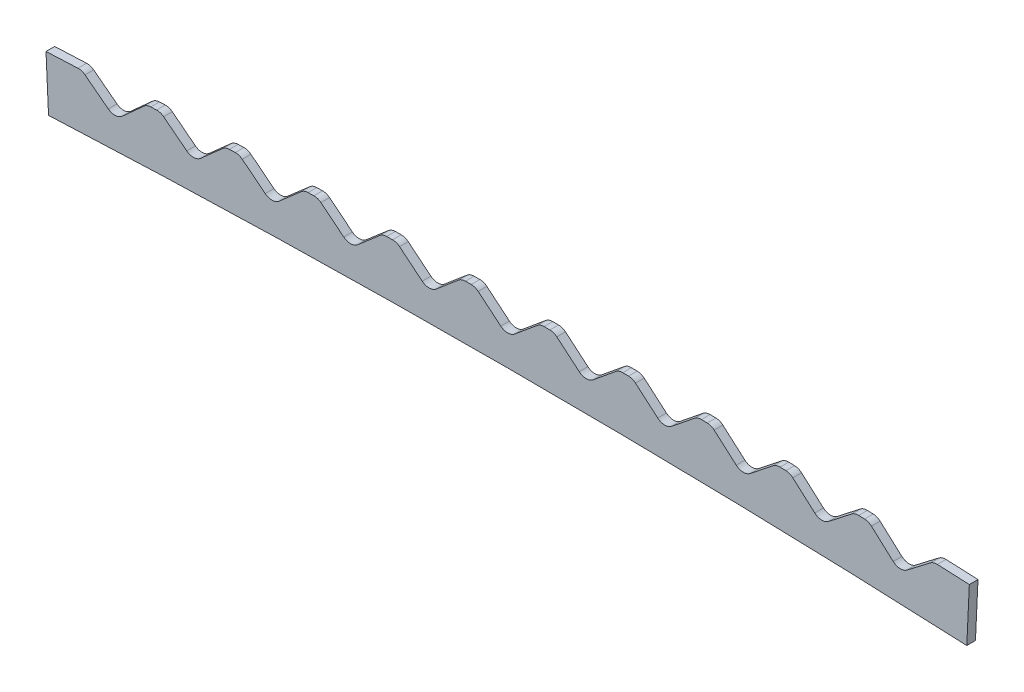
from build123d import *

# Parameters (mm, degrees)
BOSS_EXTRU_2_DEPTH                 = 8
ENL_V_MAT_EXTRU_1_DEPTH            = 9
CONG_1_R                           = 10
R_P_TITION_CIRCULAIRE1_COUNT       = 6
R_P_TITION_CIRCULAIRE1_ANGLE       = 2.3
CONG_1_OF_R_P_TITION_CIRCULAIRE1_R = 10
R_P_TITION_CIRCULAIRE2_COUNT       = 6
R_P_TITION_CIRCULAIRE2_ANGLE       = 2.3
CONG_1_OF_R_P_TITION_CIRCULAIRE2_R = 10


with BuildPart() as part:
    # Esquisse1 → Boss.-Extru.2 (new body)
    with BuildSketch(Plane.XY):
        with BuildLine():
            Line((423.958056387, -9.991125342), (426.313378922, 39.953368406))
            ThreePointArc((426.313378922, 39.953368406), (0, 50), (-426.313378922, 39.953368406))
            Line((-426.313378922, 39.953368406), (-423.958056387, -9.991125342))
            ThreePointArc((-423.958056387, -9.991125342), (0, 0), (423.958056387, -9.991125342))
        make_face()
    extrude(amount=BOSS_EXTRU_2_DEPTH)

    # Esquisse2 → Enlèv. mat.-Extru.1 (cut, through all)
    with BuildSketch(Plane.XY.offset(8)):
        Polygon((0, 25), (30, 49.950276106), (0, 74.995327729), (-30, 49.950276106), align=None)
    enl_v_mat_extru_1 = extrude(amount=-ENL_V_MAT_EXTRU_1_DEPTH, mode=Mode.SUBTRACT)

    # Congé1
    cong_1_edges = [part.edges().sort_by_distance(p)[0] for p in [
        (0, 25, 4),
        (-30, 49.950276106, 4),
        (30, 49.950276106, 4),
    ]]
    fillet(cong_1_edges, radius=CONG_1_R)

    # Répétition circulaire1: Enlèv. mat.-Extru.1 ×6 about axis
    r_p_tition_circulaire1_axis = Axis((0, -9000, 0), (0, 0, 1))
    for i in range(1, R_P_TITION_CIRCULAIRE1_COUNT):
        add(enl_v_mat_extru_1.rotate(r_p_tition_circulaire1_axis, i * R_P_TITION_CIRCULAIRE1_ANGLE / (R_P_TITION_CIRCULAIRE1_COUNT - 1)), mode=Mode.SUBTRACT)

    # Congé1 of Répétition circulaire1
    cong_1_of_r_p_tition_circulaire1_edges = [part.edges().sort_by_distance(p)[0] for p in [
        (-72.456565501, 24.709139142, 4),
        (-102.655910154, 49.417758293, 4),
        (-42.657843855, 49.899463992, 4),
        (-144.908460692, 23.836575317, 4),
        (-175.305203447, 48.301944876, 4),
        (-115.312938126, 49.265325224, 4),
        (-217.351015561, 22.382364766, 4),
        (-247.943197144, 46.602907776, 4),
        (-187.960599706, 48.047900678, 4),
        (-289.779560701, 20.346601223, 4),
        (-320.565209242, 44.320756509, 4),
        (-260.596145965, 46.247268824, 4),
        (-362.189427606, 17.729415908, 4),
        (-393.166558764, 41.455638174, 4),
        (-333.214895057, 43.863545726, 4),
    ]]
    fillet(cong_1_of_r_p_tition_circulaire1_edges, radius=CONG_1_OF_R_P_TITION_CIRCULAIRE1_R)

    # Répétition circulaire2: Enlèv. mat.-Extru.1 ×6 about axis
    r_p_tition_circulaire2_axis = Axis((0, -9000, 0), (0, 0, -1))
    for i in range(1, R_P_TITION_CIRCULAIRE2_COUNT):
        add(enl_v_mat_extru_1.rotate(r_p_tition_circulaire2_axis, i * R_P_TITION_CIRCULAIRE2_ANGLE / (R_P_TITION_CIRCULAIRE2_COUNT - 1)), mode=Mode.SUBTRACT)

    # Congé1 of Répétition circulaire2
    cong_1_of_r_p_tition_circulaire2_edges = [part.edges().sort_by_distance(p)[0] for p in [
        (72.456565501, 24.709139142, 4),
        (42.657843855, 49.899463992, 4),
        (102.655910154, 49.417758293, 4),
        (144.908460692, 23.836575317, 4),
        (115.312938126, 49.265325224, 4),
        (175.305203447, 48.301944876, 4),
        (217.351015561, 22.382364766, 4),
        (187.960599706, 48.047900678, 4),
        (247.943197144, 46.602907776, 4),
        (289.779560701, 20.346601223, 4),
        (260.596145965, 46.247268824, 4),
        (320.565209242, 44.320756509, 4),
        (362.189427606, 17.729415908, 4),
        (333.214895057, 43.863545726, 4),
        (393.166558764, 41.455638174, 4),
    ]]
    fillet(cong_1_of_r_p_tition_circulaire2_edges, radius=CONG_1_OF_R_P_TITION_CIRCULAIRE2_R)


solid = part.part
